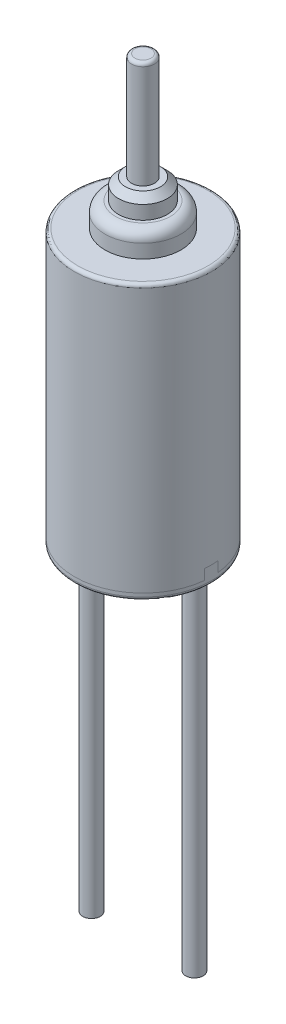
from build123d import *

# Parameters (mm, degrees)
SKETCH1_R              = 2
BOSS_EXTRUDE1_DEPTH    = 8
SKETCH2_R              = 1.105
BOSS_EXTRUDE2_DEPTH    = 0.7
SKETCH3_R              = 0.71
BOSS_EXTRUDE3_DEPTH    = 0.6
SKETCH4_R              = 0.335
BOSS_EXTRUDE4_DEPTH    = 3.11
SPLIT1_SURFACE_1_BACK  = 14.638
SPLIT1_SURFACE_1_DEPTH = 29.276
SPLIT1_SURFACE_2_BACK  = 14.638
SPLIT1_SURFACE_2_DEPTH = 29.276
FILLET1_R              = 0.1
FILLET2_R              = 0.1
FILLET3_R              = 0.3
CHAMFER1_SIZE          = 0.2
FILLET4_R              = 0.1
SKETCH6_R              = 0.255
BOSS_EXTRUDE5_DEPTH    = 10
BOSS_EXTRUDE5_2_DEPTH  = 10


with BuildPart() as part:
    # Sketch1 → Boss-Extrude1 (new body)
    with BuildSketch(Plane(origin=(0, 0, 0), x_dir=(1, 0, 0), z_dir=(0, 1, 0))):
        with Locations(Location((0, 0, 0), (0, 0, 270))):
            Circle(SKETCH1_R)
    extrude(amount=BOSS_EXTRUDE1_DEPTH)

    # Sketch2 → Boss-Extrude2 (add)
    with BuildSketch(Plane(origin=(0, 8, 0), x_dir=(1, 0, 0), z_dir=(0, 1, 0))):
        with Locations(Location((0, 0, 0), (0, 0, 270))):
            Circle(SKETCH2_R)
    extrude(amount=BOSS_EXTRUDE2_DEPTH)


with BuildPart() as body_2:
    # Sketch3 → Boss-Extrude3 (new body)
    with BuildSketch(Plane(origin=(0, 8.7, 0), x_dir=(1, 0, 0), z_dir=(0, 1, 0))):
        with Locations(Location((0, 0, 0), (0, 0, 270))):
            Circle(SKETCH3_R)
    extrude(amount=BOSS_EXTRUDE3_DEPTH)

    # Chamfer1
    chamfer1_edges = [body_2.edges().sort_by_distance(p)[0] for p in [
        (0, 9.3, -0.71),
    ]]
    chamfer(chamfer1_edges, length=CHAMFER1_SIZE)


with BuildPart() as body_3:
    # Sketch4 → Boss-Extrude4 (new body)
    with BuildSketch(Plane(origin=(0, 9.3, 0), x_dir=(1, 0, 0), z_dir=(0, 1, 0))):
        with Locations(Location((0, 0, 0), (0, 0, 270))):
            Circle(SKETCH4_R)
    extrude(amount=BOSS_EXTRUDE4_DEPTH)

    # Fillet4
    fillet4_edges = [body_3.edges().sort_by_distance(p)[0] for p in [
        (0, 12.41, -0.335),
    ]]
    fillet(fillet4_edges, radius=FILLET4_R)


with BuildPart() as body_4:
    # Split1: the piece behind the surface
    add(part.part)
    # Split1 surface: a surface, the sketch's curves swept straight by 29.276 mm
    with BuildLine(Plane(origin=(0, 0, 0), x_dir=(0, 0, -1), z_dir=(1, 0, 0)).offset(-SPLIT1_SURFACE_1_BACK), mode=Mode.PRIVATE) as split1_surface_1_path:
        Line((-2, 0.2), (-0.2, 0.2))
        Line((-0.2, 0.2), (-0.2, 0.5))
        Line((-0.2, 0.5), (0.2, 0.5))
        Line((0.2, 0.5), (0.2, 0.2))
        Line((0.2, 0.2), (2, 0.2))
    split1_surface_1 = Shell.extrude(split1_surface_1_path.wire(), (1 * SPLIT1_SURFACE_1_DEPTH, 0 * SPLIT1_SURFACE_1_DEPTH, 0 * SPLIT1_SURFACE_1_DEPTH))
    split(bisect_by=split1_surface_1, keep=Keep.BOTTOM)

    # Fillet1
    fillet1_edges = [body_4.edges().sort_by_distance(p)[0] for p in [
        (0, 0, -2),
    ]]
    fillet(fillet1_edges, radius=FILLET1_R)


with BuildPart() as part_1:
    add(part.part)

    # Split1: split by a surface, the side it looks to stays
    # Split1 surface: a surface, the sketch's curves swept straight by 29.276 mm
    with BuildLine(Plane(origin=(0, 0, 0), x_dir=(0, 0, -1), z_dir=(1, 0, 0)).offset(-SPLIT1_SURFACE_2_BACK), mode=Mode.PRIVATE) as split1_surface_2_path:
        Line((-2, 0.2), (-0.2, 0.2))
        Line((-0.2, 0.2), (-0.2, 0.5))
        Line((-0.2, 0.5), (0.2, 0.5))
        Line((0.2, 0.5), (0.2, 0.2))
        Line((0.2, 0.2), (2, 0.2))
    split1_surface_2 = Shell.extrude(split1_surface_2_path.wire(), (1 * SPLIT1_SURFACE_2_DEPTH, 0 * SPLIT1_SURFACE_2_DEPTH, 0 * SPLIT1_SURFACE_2_DEPTH))
    split(bisect_by=split1_surface_2, keep=Keep.TOP)

    # Fillet2
    fillet2_edges = [part_1.edges().sort_by_distance(p)[0] for p in [
        (0, 8, -2),
    ]]
    fillet(fillet2_edges, radius=FILLET2_R)

    # Fillet3
    fillet3_edges = [part_1.edges().sort_by_distance(p)[0] for p in [
        (0, 8.7, -1.105),
    ]]
    fillet(fillet3_edges, radius=FILLET3_R)


with BuildPart() as body_5:
    # Sketch6 → Boss-Extrude5 (new body)
    with BuildSketch(Plane.XZ):
        with Locations(Location((-1.5, 0, 0), (0, 0, 270))):
            Circle(SKETCH6_R)
    extrude(amount=BOSS_EXTRUDE5_DEPTH)


with BuildPart() as body_6:
    # Sketch6 → Boss-Extrude5 2 (new body)
    with BuildSketch(Plane.XZ):
        with Locations(Location((1.5, 0, 0), (0, 0, 90))):
            Circle(SKETCH6_R)
    extrude(amount=BOSS_EXTRUDE5_2_DEPTH)


solid = Compound([body_2.part, body_3.part, body_4.part, part_1.part, body_5.part, body_6.part])
